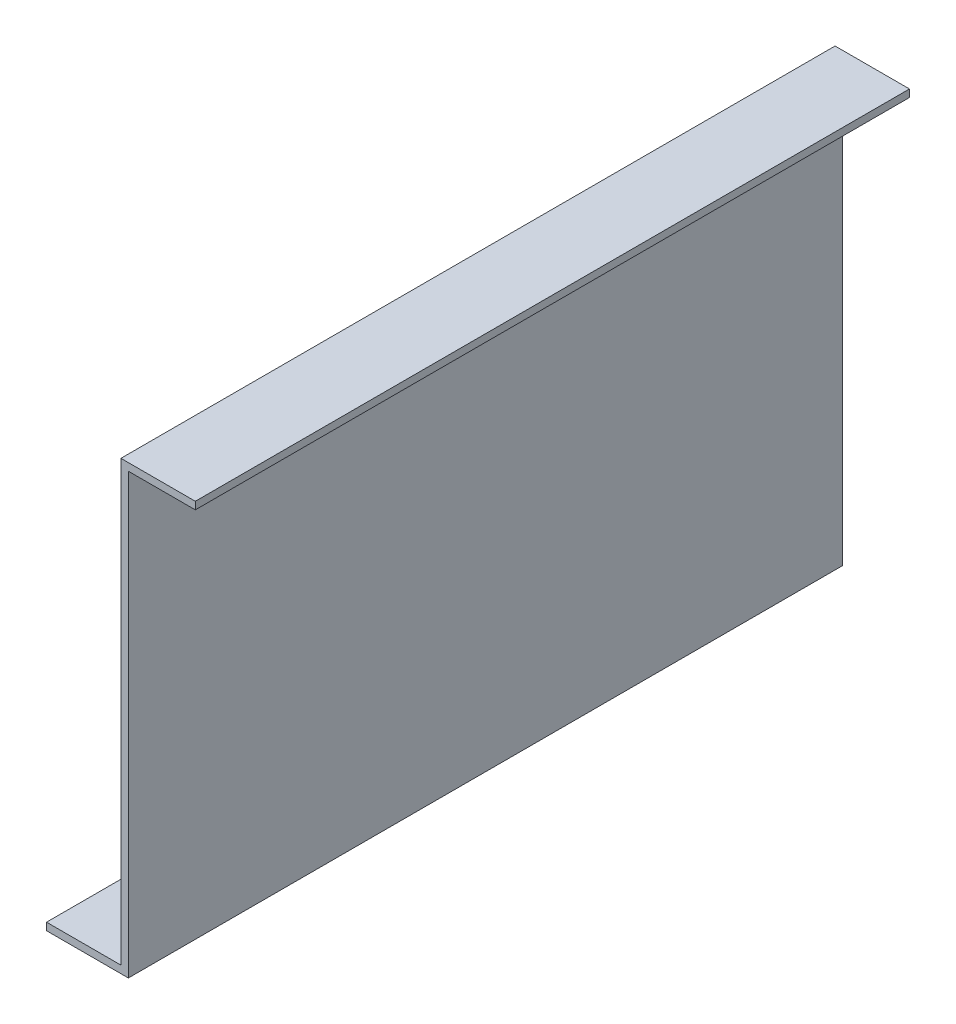
from build123d import *

# Parameters (mm, degrees)
EXTRU_MINCE1_DEPTH = 192


with BuildPart() as part:
    # Esquisse1 → Extru.-Mince1 (new body)
    with BuildSketch(Plane.XY):
        Polygon((0, 0), (20, 0), (20, 118), (40, 118), (40, 116), (22, 116), (22, -2), (0, -2), align=None)
    extrude(amount=EXTRU_MINCE1_DEPTH)


solid = part.part
